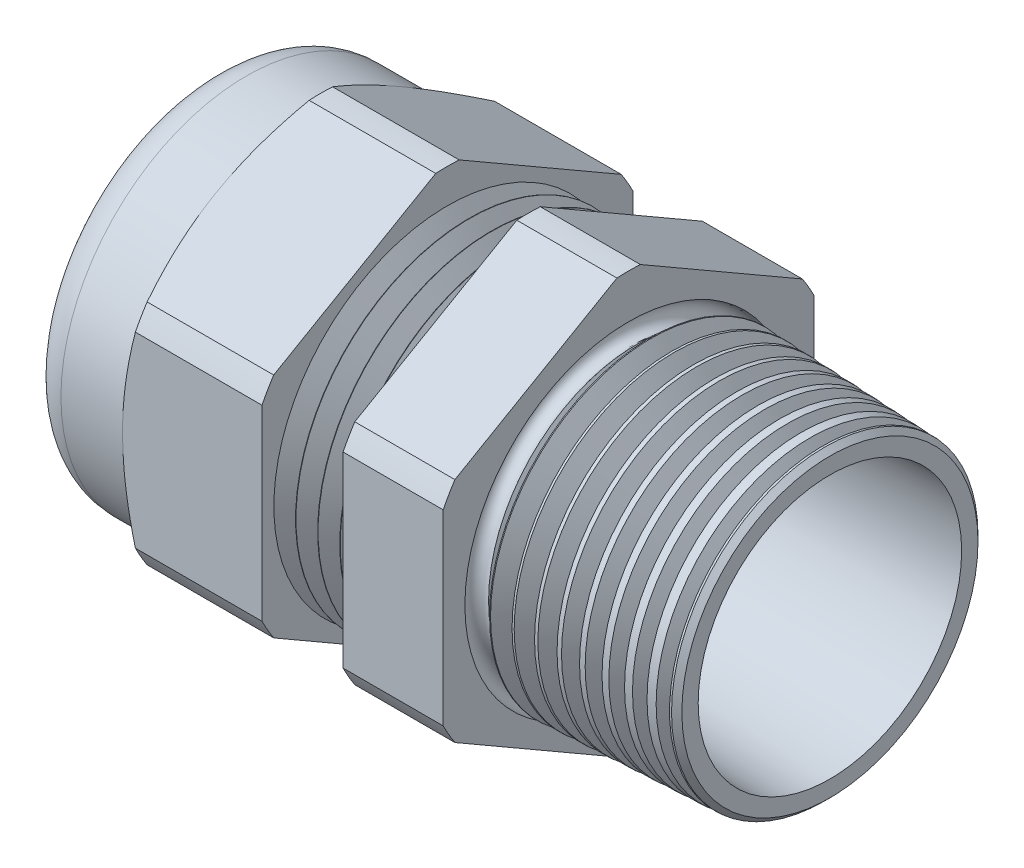
from build123d import *

# Parameters (mm, degrees)
SKETCH2_OUTSIDE_W  = 39.734
SKETCH2_OUTSIDE_H  = 39.734
CUT_EXTRUDE1_DEPTH = 20.6375
SKETCH14_W         = 6.2865
SKETCH14_H         = 1.397
CHAMFER1_SIZE      = 0.332311511
CHAMFER1_SIZE2     = 0.3175
SKETCH3_OUTSIDE_W  = 156.43
SKETCH3_OUTSIDE_H  = 159.296
SKETCH3_OUTSIDE_R  = 11.938
CUT_EXTRUDE2_DEPTH = 34.5915
CUT_EXTRUDE2_DRAFT = -60
SKETCH9_W          = 5.7785
SKETCH9_H          = 1.2319
FILLET1_R          = 2.32156
LPATTERN1_COUNT    = 4
LPATTERN1_PITCH    = 1.4224
LPATTERN2_COUNT    = 10
LPATTERN2_PITCH    = 1.4224
SKETCH15_R         = 0.635
FILLET3_R          = 0.254


with BuildPart() as part:
    # Sketch1 → Revolve1 (revolve)
    with BuildSketch(Plane.XY, mode=Mode.PRIVATE) as revolve1_sk:
        Polygon((-11.662833333, 11.17346), (-11.662833333, 13.37056), (-20.6375, 13.37056), (-20.6375, 10.541), (-26.924, 10.541), (-26.924, 8.8519), (-20.6375, 8.8519), (-20.6375, 7.62), (-11.662833333, 7.62), (12.954, 8.479638762), (12.954, 9.848416146), (0, 10.414), (0, 13.37056), (-6.444776119, 13.37056), (-6.444776119, 11.17346), align=None)
    revolve(revolve1_sk.sketch.rotate(Axis((-18.386021217, 0, 0), (1, 0, 0)), 90), axis=Axis((-18.386021217, 0, 0), (1, 0, 0)))  # turned: the seam where the file's is

    # Sketch2 outside → Cut-Extrude1 (cut)
    with BuildSketch(Plane(origin=(0, 0, 0), x_dir=(0, 0, -1), z_dir=(1, 0, 0))):
        Rectangle(SKETCH2_OUTSIDE_W, SKETCH2_OUTSIDE_H)
        with BuildLine():
            Line((11.938, -6.021298092), (11.938, 6.021298092))
            ThreePointArc((11.938, 6.021298092), (11.579244623, 6.68528), (11.183597111, 7.327962224))
            Line((11.183597111, 7.327962224), (0.754402889, 13.349260316))
            ThreePointArc((0.754402889, 13.349260316), (0, 13.37056), (-0.754402889, 13.349260316))
            Line((-0.754402889, 13.349260316), (-11.183597111, 7.327962224))
            ThreePointArc((-11.183597111, 7.327962224), (-11.579244623, 6.68528), (-11.938, 6.021298092))
            Line((-11.938, 6.021298092), (-11.938, -6.021298092))
            ThreePointArc((-11.938, -6.021298092), (-11.579244623, -6.68528), (-11.183597111, -7.327962224))
            Line((-11.183597111, -7.327962224), (-0.754402889, -13.349260316))
            ThreePointArc((-0.754402889, -13.349260316), (0, -13.37056), (0.754402889, -13.349260316))
            Line((0.754402889, -13.349260316), (11.183597111, -7.327962224))
            ThreePointArc((11.183597111, -7.327962224), (11.579244623, -6.68528), (11.938, -6.021298092))
        make_face(mode=Mode.SUBTRACT)
    extrude(amount=-CUT_EXTRUDE1_DEPTH, mode=Mode.SUBTRACT)

    # Sketch14 → Revolve4 (revolve)
    with BuildSketch(Plane.XY, mode=Mode.PRIVATE) as revolve4_sk:
        with Locations((-23.78075, 11.2395)):
            Rectangle(SKETCH14_W, SKETCH14_H)
    revolve(revolve4_sk.sketch.rotate(Axis((-18.386021217, 0, 0), (1, 0, 0)), 90), axis=Axis((-18.386021217, 0, 0), (1, 0, 0)))  # turned: the seam where the file's is

    # Chamfer1
    chamfer1_edges = [part.edges().sort_by_distance(p)[0] for p in [
        (12.954, 0, -9.848416146),
    ]]
    chamfer1_side = [part.faces().sort_by_distance(p)[0] for p in [
        (6.477, 0, -10.131208073),
    ]]
    chamfer(chamfer1_edges, length=CHAMFER1_SIZE, length2=CHAMFER1_SIZE2, reference=chamfer1_side[0])


with BuildPart() as cut_extrude2_tool:
    # Sketch3 outside → Cut-Extrude2 (with draft: the straight prism first)
    with BuildSketch(Plane.ZY.offset(20.6375)):
        Rectangle(SKETCH3_OUTSIDE_W, SKETCH3_OUTSIDE_H)
        Circle(SKETCH3_OUTSIDE_R, mode=Mode.SUBTRACT)
    extrude(amount=-CUT_EXTRUDE2_DEPTH)
    # Cut-Extrude2: the draft: its side faces are tilted about the plane it starts from
    cut_extrude2_sides = [cut_extrude2_tool.faces().sort_by_distance(p)[0] for p in [
        (-3.34175, -79.648, 0),
        (-3.34175, 0, 78.215),
        (-3.34175, 79.648, 0),
        (-3.34175, 0, -78.215),
        (-3.34175, 0, -11.938),
    ]]
    draft(cut_extrude2_sides, Plane.ZY.offset(20.6375), CUT_EXTRUDE2_DRAFT)


with BuildPart() as part_1:
    add(part.part)

    # Cut-Extrude2: cut by cut_extrude2_tool
    add(cut_extrude2_tool.part, mode=Mode.SUBTRACT)

    # Fillet1
    fillet1_edges = [part_1.edges().sort_by_distance(p)[0] for p in [
        (-26.924, 0, -11.938),
    ]]
    fillet(fillet1_edges, radius=FILLET1_R)

    # Sketch10 → Cut-Revolve1 (revolve, cut)
    with BuildSketch(Plane.XY, mode=Mode.PRIVATE) as cut_revolve1_sk:
        Polygon((-11.662833333, 11.17346), (-10.964333659, 9.963623075), (-10.265833985, 11.17346), align=None)
    cut_revolve1 = revolve(cut_revolve1_sk.sketch.rotate(Axis((15.58962545, 0, 0), (-1, 0, 0)), 90), axis=Axis((15.58962545, 0, 0), (-1, 0, 0)), mode=Mode.SUBTRACT)  # turned: the seam where the file's is

    # LPattern1: Cut-Revolve1 ×4
    with Locations(*[(i * LPATTERN1_PITCH, 0, 0) for i in range(1, LPATTERN1_COUNT)]):
        add(cut_revolve1, mode=Mode.SUBTRACT)

    # Sketch13 → Cut-Revolve2 (revolve, cut)
    with BuildSketch(Plane.XY, mode=Mode.PRIVATE) as cut_revolve2_sk:
        Polygon((0, 10.414), (1.39921935, 10.352908764), (0.717245196, 9.17169488), align=None)
    cut_revolve2 = revolve(cut_revolve2_sk.sketch.rotate(Axis((-18.386021217, 0, 0), (1, 0, 0)), 270), axis=Axis((-18.386021217, 0, 0), (1, 0, 0)), mode=Mode.SUBTRACT)  # turned: the seam where the file's is

    # LPattern2: Cut-Revolve2 ×10
    with Locations(*[(i * LPATTERN2_PITCH, 0, 0) for i in range(1, LPATTERN2_COUNT)]):
        add(cut_revolve2, mode=Mode.SUBTRACT)

    # Sketch15 → Cut-Revolve4 (revolve, cut)
    with BuildSketch(Plane.XY, mode=Mode.PRIVATE) as cut_revolve4_sk:
        with Locations((0, -9.906)):
            Circle(SKETCH15_R)
    revolve(cut_revolve4_sk.sketch.rotate(Axis((10.155027747, 0, 0), (-1, 0, 0)), 90), axis=Axis((10.155027747, 0, 0), (-1, 0, 0)), mode=Mode.SUBTRACT)  # turned: the seam where the file's is


with BuildPart() as body_2:
    # Sketch9 → Revolve3 (revolve)
    with BuildSketch(Plane.XY, mode=Mode.PRIVATE) as revolve3_sk:
        with Locations((-23.52675, 8.23595)):
            Rectangle(SKETCH9_W, SKETCH9_H)
    revolve(revolve3_sk.sketch.rotate(Axis((8.695207459, 0, 0), (-1, 0, 0)), 270), axis=Axis((8.695207459, 0, 0), (-1, 0, 0)))  # turned: the seam where the file's is

    # Fillet3
    fillet3_edges = [body_2.edges().sort_by_distance(p)[0] for p in [
        (-26.416, 0, -8.8519),
    ]]
    fillet(fillet3_edges, radius=FILLET3_R)


solid = Compound([part_1.part, body_2.part])
